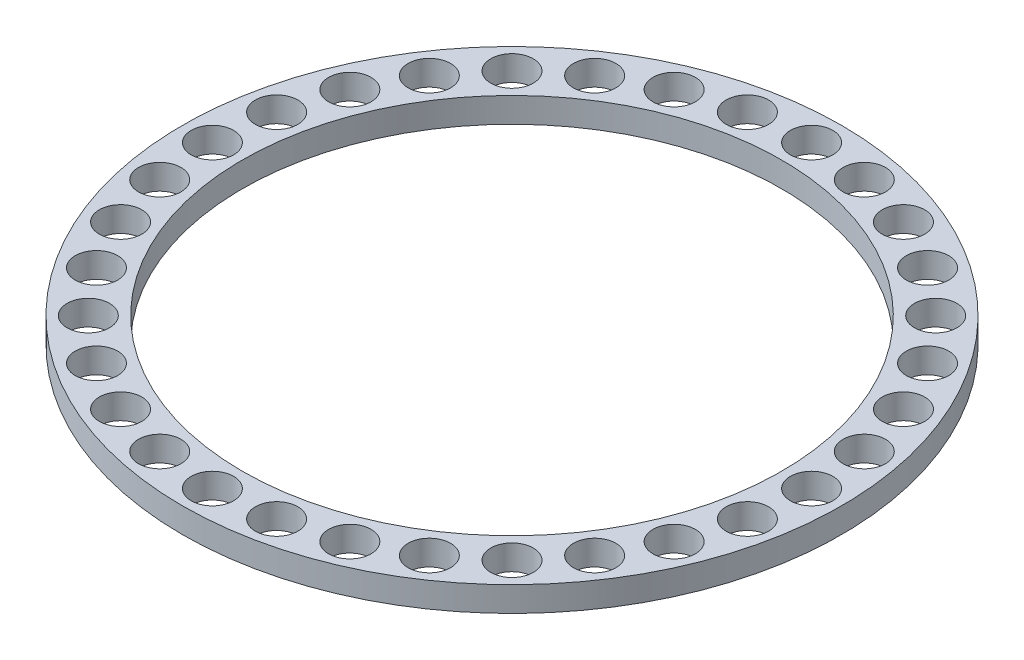
from build123d import *

# Parameters (mm, degrees)
SKETCH1_R           = 66
SKETCH1_R_2         = 54
SKETCH1_R_3         = 4.25
BOSS_EXTRUDE1_DEPTH = 5


with BuildPart() as part:
    # Sketch1 → Boss-Extrude1 (new body)
    with BuildSketch(Plane(origin=(0, 0, 0), x_dir=(1, 0, 0), z_dir=(0, 1, 0))):
        Circle(SKETCH1_R)
        Circle(SKETCH1_R_2, mode=Mode.SUBTRACT)
        with Locations((0, 60)):
            Circle(SKETCH1_R_3, mode=Mode.SUBTRACT)
        with Locations((11.705419321, 58.847116824)):
            Circle(SKETCH1_R_3, mode=Mode.SUBTRACT)
        with Locations((22.961005942, 55.432771951)):
            Circle(SKETCH1_R_3, mode=Mode.SUBTRACT)
        with Locations((33.334213981, 49.888176738)):
            Circle(SKETCH1_R_3, mode=Mode.SUBTRACT)
        with Locations((42.426406871, 42.426406871)):
            Circle(SKETCH1_R_3, mode=Mode.SUBTRACT)
        with Locations((49.888176738, 33.334213981)):
            Circle(SKETCH1_R_3, mode=Mode.SUBTRACT)
        with Locations((55.432771951, 22.961005942)):
            Circle(SKETCH1_R_3, mode=Mode.SUBTRACT)
        with Locations((58.847116824, 11.705419321)):
            Circle(SKETCH1_R_3, mode=Mode.SUBTRACT)
        with Locations((60, 0)):
            Circle(SKETCH1_R_3, mode=Mode.SUBTRACT)
        with Locations((58.847116824, -11.705419321)):
            Circle(SKETCH1_R_3, mode=Mode.SUBTRACT)
        with Locations((55.432771951, -22.961005942)):
            Circle(SKETCH1_R_3, mode=Mode.SUBTRACT)
        with Locations((49.888176738, -33.334213981)):
            Circle(SKETCH1_R_3, mode=Mode.SUBTRACT)
        with Locations((42.426406871, -42.426406871)):
            Circle(SKETCH1_R_3, mode=Mode.SUBTRACT)
        with Locations((33.334213981, -49.888176738)):
            Circle(SKETCH1_R_3, mode=Mode.SUBTRACT)
        with Locations((22.961005942, -55.432771951)):
            Circle(SKETCH1_R_3, mode=Mode.SUBTRACT)
        with Locations((11.705419321, -58.847116824)):
            Circle(SKETCH1_R_3, mode=Mode.SUBTRACT)
        with Locations((0, -60)):
            Circle(SKETCH1_R_3, mode=Mode.SUBTRACT)
        with Locations((-11.705419321, -58.847116824)):
            Circle(SKETCH1_R_3, mode=Mode.SUBTRACT)
        with Locations((-22.961005942, -55.432771951)):
            Circle(SKETCH1_R_3, mode=Mode.SUBTRACT)
        with Locations((-33.334213981, -49.888176738)):
            Circle(SKETCH1_R_3, mode=Mode.SUBTRACT)
        with Locations((-42.426406871, -42.426406871)):
            Circle(SKETCH1_R_3, mode=Mode.SUBTRACT)
        with Locations((-49.888176738, -33.334213981)):
            Circle(SKETCH1_R_3, mode=Mode.SUBTRACT)
        with Locations((-55.432771951, -22.961005942)):
            Circle(SKETCH1_R_3, mode=Mode.SUBTRACT)
        with Locations((-58.847116824, -11.705419321)):
            Circle(SKETCH1_R_3, mode=Mode.SUBTRACT)
        with Locations((-60, 0)):
            Circle(SKETCH1_R_3, mode=Mode.SUBTRACT)
        with Locations((-58.847116824, 11.705419321)):
            Circle(SKETCH1_R_3, mode=Mode.SUBTRACT)
        with Locations((-55.432771951, 22.961005942)):
            Circle(SKETCH1_R_3, mode=Mode.SUBTRACT)
        with Locations((-49.888176738, 33.334213981)):
            Circle(SKETCH1_R_3, mode=Mode.SUBTRACT)
        with Locations((-42.426406871, 42.426406871)):
            Circle(SKETCH1_R_3, mode=Mode.SUBTRACT)
        with Locations((-33.334213981, 49.888176738)):
            Circle(SKETCH1_R_3, mode=Mode.SUBTRACT)
        with Locations((-22.961005942, 55.432771951)):
            Circle(SKETCH1_R_3, mode=Mode.SUBTRACT)
        with Locations((-11.705419321, 58.847116824)):
            Circle(SKETCH1_R_3, mode=Mode.SUBTRACT)
    extrude(amount=BOSS_EXTRUDE1_DEPTH)


solid = part.part
